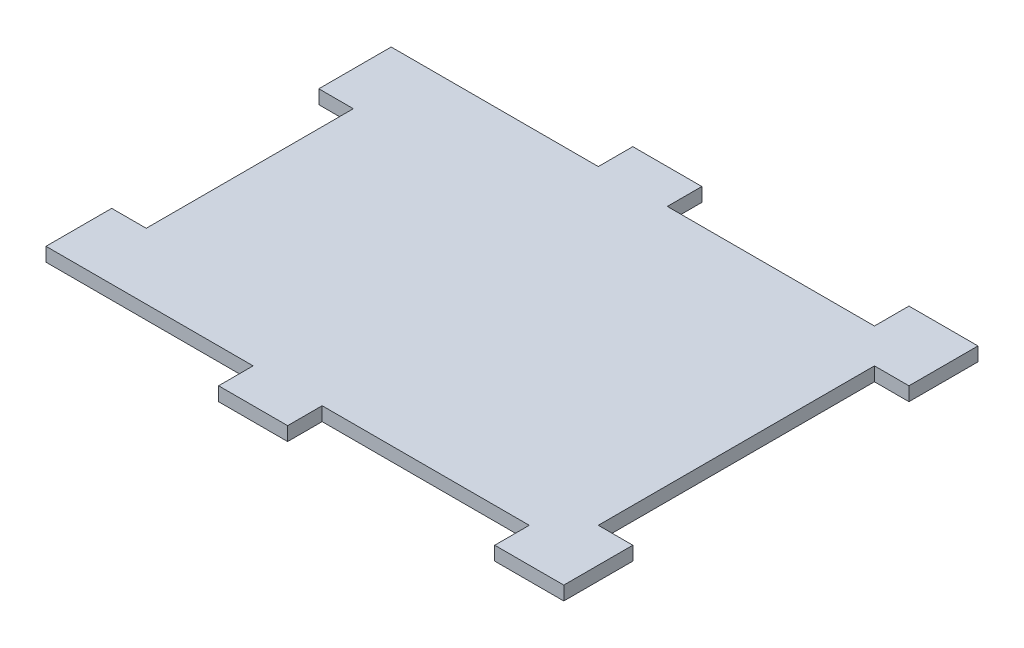
from build123d import *

# Parameters (mm, degrees)
BOSS_EXTRUDE1_DEPTH = 2.54


with BuildPart() as part:
    # Sketch2 → Boss-Extrude1 (new body)
    with BuildSketch(Plane(origin=(0, -382.641338205, 0), x_dir=(1, 0, 0), z_dir=(0, 1, 0))):
        Polygon((72.335513148, -59.914580045), (78.685513148, -59.914580045), (78.685513148, -47.214580045), (65.985513148, -47.214580045), (65.985513148, -53.564580045), (27.885513148, -53.564580045), (27.885513148, -47.214580045), (15.185513148, -47.214580045), (15.185513148, -53.564580045), (-22.914486852, -53.564580045), (-22.914486852, -66.87715292), (-16.564486852, -66.87715292), (-16.564486852, -104.97715292), (-22.914486852, -104.97715292), (-22.914486852, -117.064580045), (15.185513148, -117.064580045), (15.185513148, -123.414580045), (27.885513148, -123.414580045), (27.885513148, -117.064580045), (65.985513148, -117.064580045), (65.985513148, -123.414580045), (78.685513148, -123.414580045), (78.685513148, -110.714580045), (72.335513148, -110.714580045), align=None)
    extrude(amount=BOSS_EXTRUDE1_DEPTH)


solid = part.part
